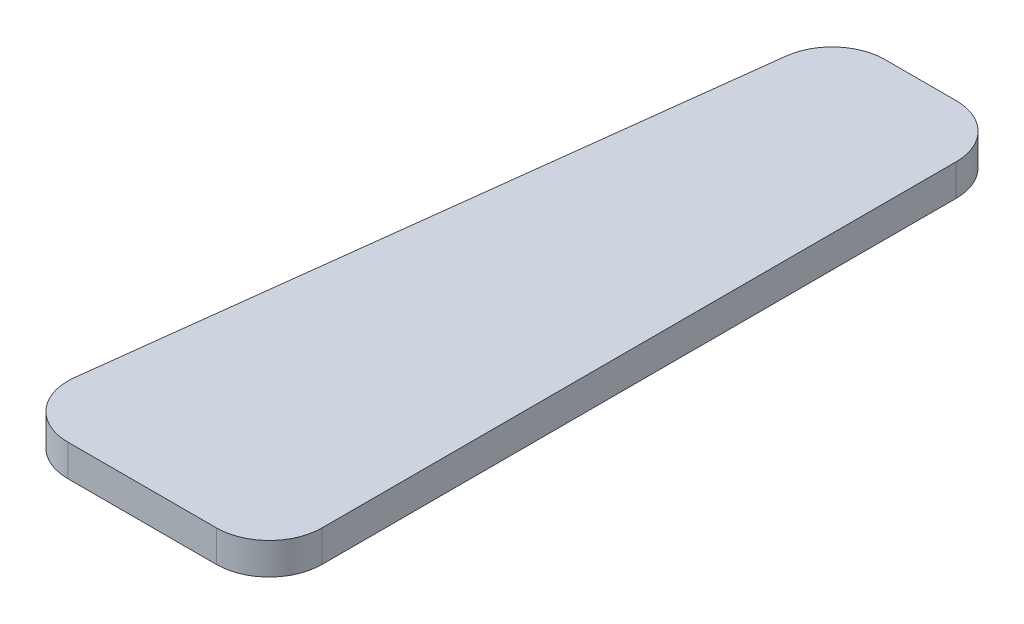
from build123d import *

# Parameters (mm, degrees)
BOSS_EXTRUDE1_DEPTH = 3


with BuildPart() as part:
    # Sketch1 → Boss-Extrude1 (new body)
    with BuildSketch(Plane(origin=(0, 0, 0), x_dir=(1, 0, 0), z_dir=(0, 1, 0))):
        with BuildLine():
            Line((-3.651788018, 29.785313531), (-10.968861189, -30.214686469))
            ThreePointArc((-10.968861189, -30.214686469), (-9.749049984, -34.134595628), (-6.005631801, -35.819958346))
            Line((-6.005631801, -35.819958346), (8.055527666, -35.819958346))
            ThreePointArc((8.055527666, -35.819958346), (11.591061572, -34.355492252), (13.055527666, -30.819958346))
            Line((13.055527666, -30.819958346), (13.055527666, 29.180041654))
            ThreePointArc((13.055527666, 29.180041654), (11.591061572, 32.71557556), (8.055527666, 34.180041654))
            Line((8.055527666, 34.180041654), (1.31144137, 34.180041654))
            ThreePointArc((1.31144137, 34.180041654), (-2.003195912, 32.923459837), (-3.651788018, 29.785313531))
        make_face()
    extrude(amount=BOSS_EXTRUDE1_DEPTH)


solid = part.part
